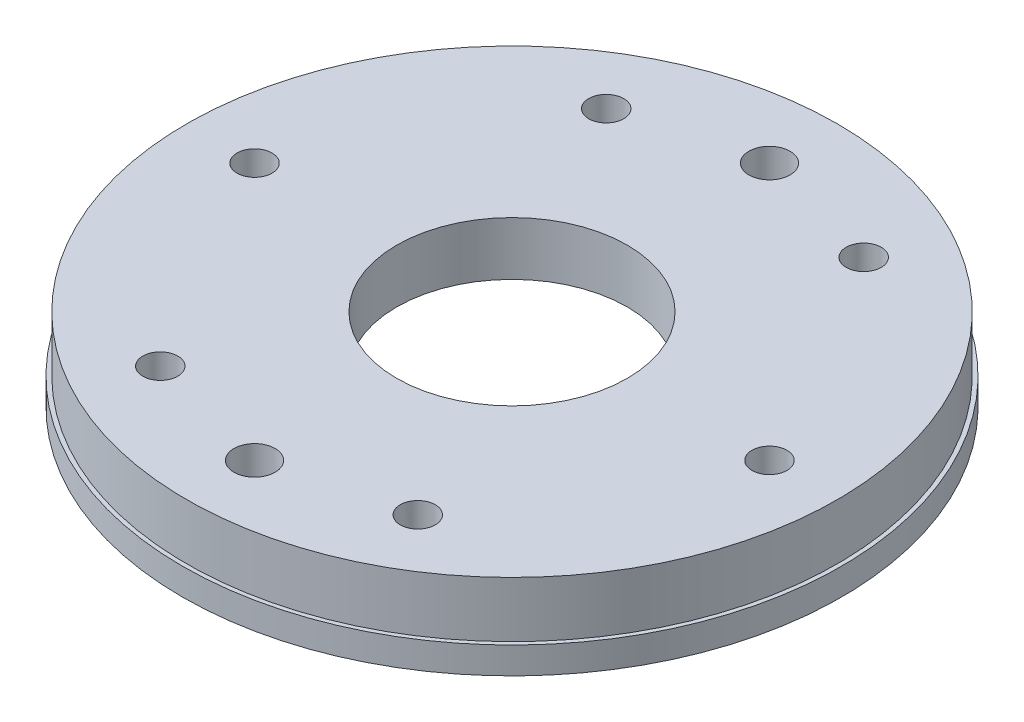
from build123d import *

# Parameters (mm, degrees)
SCHIZZO2_R                  = 28
TAGLIO_ESTRUSIONE1_DEPTH    = 21
RIPETIZIONECIRCOLARE1_COUNT = 6
SCHIZZO5_R                  = 5
TAGLIO_ESTRUSIONE2_DEPTH    = 21
SCHIZZO6_R                  = 40
TAGLIO_ESTRUSIONE3_DEPTH    = 7


with BuildPart() as part:
    # Schizzo1 → Rivoluzione1 (revolve)
    with BuildSketch(Plane.XY):
        Polygon((0, 0), (80, 0), (80, 6.5), (79, 6.5), (79, 20), (0, 20), align=None)
    revolve(axis=Axis((0, 0, 0), (0, 1, 0)))

    # Schizzo2 → Taglio-Estrusione1 (cut, through all)
    with BuildSketch(Plane.XZ):
        Circle(SCHIZZO2_R)
    extrude(amount=-TAGLIO_ESTRUSIONE1_DEPTH, mode=Mode.SUBTRACT)

    # Schizzo3 → M10 Foro filettato profondo1 (revolve, cut)
    with BuildSketch(Plane(origin=(62.5, 0, 0), x_dir=(0, 0, -1), z_dir=(1, 0, 0))):
        Polygon((0, 0), (0, 27.553657631), (4.25, 25), (4.25, 0), align=None)
    m10_foro_filettato_profondo1 = revolve(axis=Axis((62.5, -6.35, 0), (0, 1, 0)), mode=Mode.SUBTRACT)

    # RipetizioneCircolare1: M10 Foro filettato profondo1 ×6 about axis
    ripetizionecircolare1_axis = Axis((0, 0, 0), (0, 1, 0))
    for i in range(1, RIPETIZIONECIRCOLARE1_COUNT):
        add(m10_foro_filettato_profondo1.rotate(ripetizionecircolare1_axis, i * 360 / RIPETIZIONECIRCOLARE1_COUNT), mode=Mode.SUBTRACT)

    # Schizzo5 → Taglio-Estrusione2 (cut, through all)
    with BuildSketch(Plane.XZ):
        with Locations((0, 62.5)):
            Circle(SCHIZZO5_R)
        with Locations((0, -62.5)):
            Circle(SCHIZZO5_R)
    extrude(amount=-TAGLIO_ESTRUSIONE2_DEPTH, mode=Mode.SUBTRACT)

    # Schizzo6 → Taglio-Estrusione3 (cut)
    with BuildSketch(Plane.XZ):
        Circle(SCHIZZO6_R)
    extrude(amount=-TAGLIO_ESTRUSIONE3_DEPTH, mode=Mode.SUBTRACT)


solid = part.part
